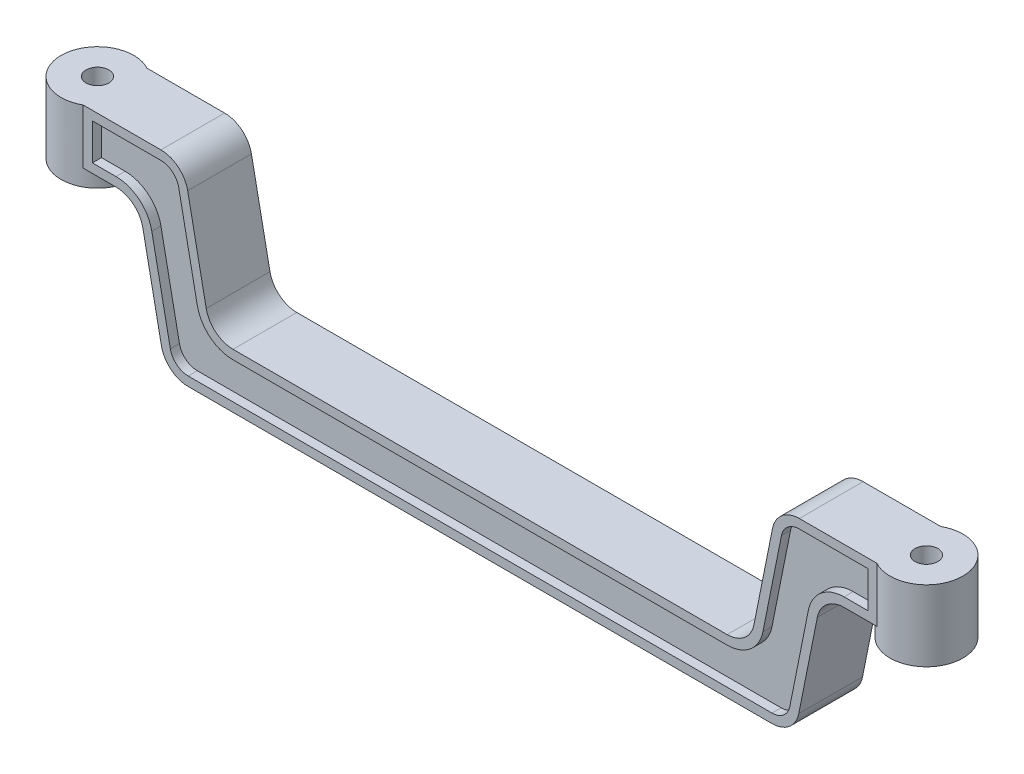
from build123d import *

# Parameters (mm, degrees)
BOSS_EXTRUDE2_DEPTH = 7
SKETCH2_R           = 4
BOSS_EXTRUDE3_DEPTH = 7.8
SKETCH3_R           = 1.25
CUT_EXTRUDE1_DEPTH  = 7.8
FILLET1_R           = 3
FILLET2_R           = 3
CUT_EXTRUDE2_DEPTH  = 1


with BuildPart() as part:
    # Sketch1 → Boss-Extrude2 (new body)
    with BuildSketch(Plane.XY):
        Polygon((-34.5, 0), (34.5, 0), (37.5, 15), (45.5, 15), (45.5, 21), (34.5, 21), (32.581176584, 21), (29.581176584, 6), (-29.581176584, 6), (-32.581176584, 21), (-45.5, 21), (-45.5, 15), (-37.5, 15), align=None)
    extrude(amount=BOSS_EXTRUDE2_DEPTH)

    # Sketch2 → Boss-Extrude3 (add)
    with BuildSketch(Plane(origin=(0, 21, 0), x_dir=(1, 0, 0), z_dir=(0, 1, 0))):
        with Locations((45.5, -3.5)):
            Circle(SKETCH2_R)
    boss_extrude3 = extrude(amount=-BOSS_EXTRUDE3_DEPTH)

    # Mirror1: Boss-Extrude3 across plane
    add(boss_extrude3.mirror(Plane(origin=(0, 0, 0), x_dir=(0, 0, 1), z_dir=(1, 0, 0))))

    # Sketch3 → Cut-Extrude1 (cut)
    with BuildSketch(Plane(origin=(0, 21, 0), x_dir=(1, 0, 0), z_dir=(0, 1, 0))):
        with Locations((45.5, -3.5)):
            Circle(SKETCH3_R)
    cut_extrude1 = extrude(amount=-CUT_EXTRUDE1_DEPTH, mode=Mode.SUBTRACT)

    # Mirror2: Cut-Extrude1 across plane
    add(cut_extrude1.mirror(Plane(origin=(0, 0, 0), x_dir=(0, 0, 1), z_dir=(1, 0, 0))), mode=Mode.SUBTRACT)

    # Fillet1
    fillet1_edges = [part.edges().sort_by_distance(p)[0] for p in [
        (34.5, 0, 3.5),
        (29.581176584, 6, 3.5),
    ]]
    fillet(fillet1_edges, radius=FILLET1_R)

    # Fillet2
    fillet2_edges = [part.edges().sort_by_distance(p)[0] for p in [
        (37.5, 15, 3.5),
        (-34.5, 0, 3.5),
        (-37.5, 15, 3.5),
        (-32.581176584, 21, 3.5),
        (-29.581176584, 6, 3.5),
        (32.581176584, 21, 3.5),
    ]]
    fillet(fillet2_edges, radius=FILLET2_R)

    # Sketch4 → Cut-Extrude2 (cut)
    with BuildSketch(Plane.XY.offset(7)):
        with BuildLine():
            Line((-36.037089005, 12.784464541), (-34.001749643, 2.60776773))
            ThreePointArc((-34.001749643, 2.60776773), (-33.308566103, 1.453315717), (-32.040588292, 1))
            Line((-32.040588292, 1), (32.040588292, 1))
            ThreePointArc((32.040588292, 1), (33.308566103, 1.453315717), (34.001749643, 2.60776773))
            Line((34.001749643, 2.60776773), (36.037089005, 12.784464541))
            ThreePointArc((36.037089005, 12.784464541), (37.423456086, 15.093368565), (39.959411708, 16))
            Line((39.959411708, 16), (42.563508327, 16))
            Line((42.563508327, 16), (42.563508327, 20))
            Line((42.563508327, 20), (35.040588292, 20))
            ThreePointArc((35.040588292, 20), (33.772610481, 19.546684283), (33.07942694, 18.39223227))
            Line((33.07942694, 18.39223227), (31.044087578, 8.215535459))
            ThreePointArc((31.044087578, 8.215535459), (29.657720498, 5.906631435), (27.121764876, 5))
            Line((27.121764876, 5), (-27.121764876, 5))
            ThreePointArc((-27.121764876, 5), (-29.657720498, 5.906631435), (-31.044087578, 8.215535459))
            Line((-31.044087578, 8.215535459), (-33.07942694, 18.39223227))
            ThreePointArc((-33.07942694, 18.39223227), (-33.772610481, 19.546684283), (-35.040588292, 20))
            Line((-35.040588292, 20), (-42.563508327, 20))
            Line((-42.563508327, 20), (-42.563508327, 16))
            Line((-42.563508327, 16), (-39.959411708, 16))
            ThreePointArc((-39.959411708, 16), (-37.423456086, 15.093368565), (-36.037089005, 12.784464541))
        make_face()
    extrude(amount=-CUT_EXTRUDE2_DEPTH, mode=Mode.SUBTRACT)


solid = part.part
